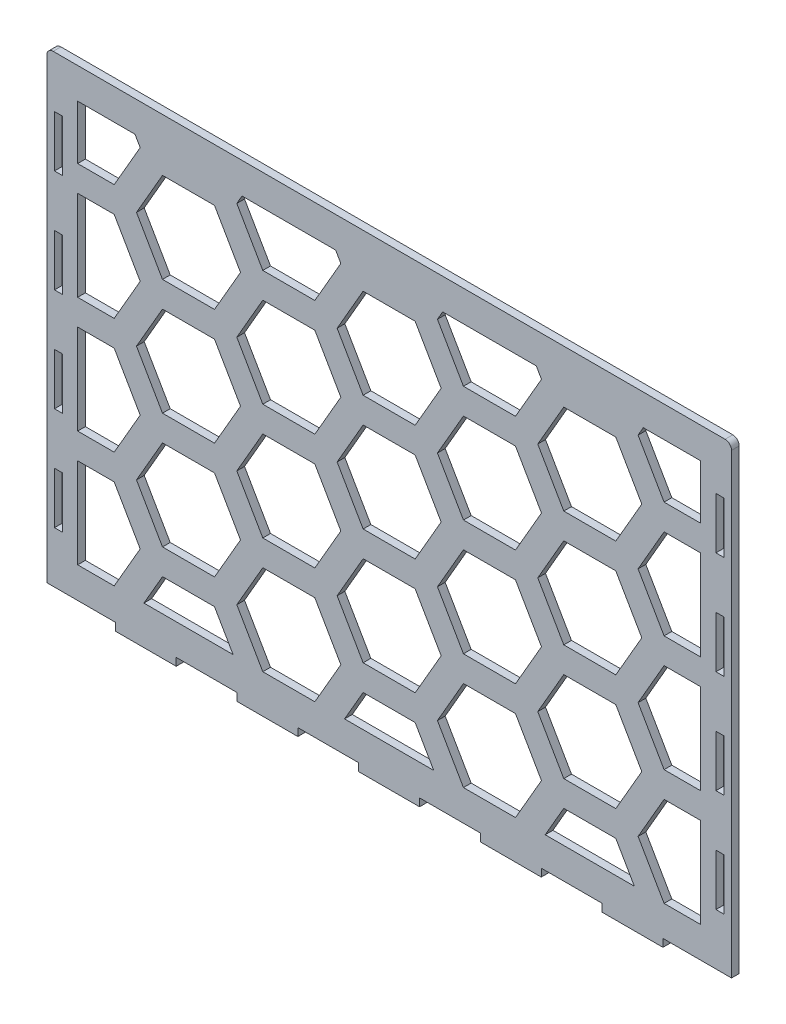
from build123d import *

# Parameters (mm, degrees)
SKETCH1_W           = 266
SKETCH1_H           = 180
SKETCH1_W_2         = 3.05
SKETCH1_H_2         = 20
SKETCH1_W_3         = 23.636363636
SKETCH1_H_3         = 3
SKETCH1_W_4         = 23.636363637
BOSS_EXTRUDE1_DEPTH = 3
FILLET1_R           = 2.5
CUT_EXTRUDE1_DEPTH  = 10


with BuildPart() as part:
    # Sketch1 → Boss-Extrude1 (new body)
    with BuildSketch(Plane.XY):
        Rectangle(SKETCH1_W, SKETCH1_H)
        with Locations((128.475, -20)):
            Rectangle(SKETCH1_W_2, SKETCH1_H_2, mode=Mode.SUBTRACT)
        with Locations((128.475, 20)):
            Rectangle(SKETCH1_W_2, SKETCH1_H_2, mode=Mode.SUBTRACT)
        with Locations((128.475, 60)):
            Rectangle(SKETCH1_W_2, SKETCH1_H_2, mode=Mode.SUBTRACT)
        with Locations((128.475, -60)):
            Rectangle(SKETCH1_W_2, SKETCH1_H_2, mode=Mode.SUBTRACT)
        with Locations((-128.475, 60)):
            Rectangle(SKETCH1_W_2, SKETCH1_H_2, mode=Mode.SUBTRACT)
        with Locations((-128.475, 20)):
            Rectangle(SKETCH1_W_2, SKETCH1_H_2, mode=Mode.SUBTRACT)
        with Locations((-128.475, -20)):
            Rectangle(SKETCH1_W_2, SKETCH1_H_2, mode=Mode.SUBTRACT)
        with Locations((-128.475, -60)):
            Rectangle(SKETCH1_W_2, SKETCH1_H_2, mode=Mode.SUBTRACT)
        with Locations((0, -91.5)):
            Rectangle(SKETCH1_W_3, SKETCH1_H_3)
        with Locations((47.272727273, -91.5)):
            Rectangle(SKETCH1_W_3, SKETCH1_H_3)
        with Locations((94.545454546, -91.5)):
            Rectangle(SKETCH1_W_4, SKETCH1_H_3)
        with Locations((-47.272727273, -91.5)):
            Rectangle(SKETCH1_W_3, SKETCH1_H_3)
        with Locations((-94.545454546, -91.5)):
            Rectangle(SKETCH1_W_4, SKETCH1_H_3)
    extrude(amount=BOSS_EXTRUDE1_DEPTH)

    # Fillet1
    fillet1_edges = [part.edges().sort_by_distance(p)[0] for p in [
        (-133, 90, 1.5),
        (133, 90, 1.5),
    ]]
    fillet(fillet1_edges, radius=FILLET1_R)

    # Sketch3 → Cut-Extrude1 (cut)
    with BuildSketch(Plane(origin=(0, 0, 0), x_dir=(-1, 0, 0), z_dir=(0, 0, -1))):
        Polygon((-121, -43), (-121, -78), (-106.8097998, -78), (-96.706170089, -60.5), (-106.8097998, -43), align=None)
        Polygon((-67.83865663, -55.5), (-57.735026919, -38), (-67.83865663, -20.5), (-88.045916051, -20.5), (-98.149545762, -38), (-88.045916051, -55.5), align=None)
        Polygon((-121, 2), (-121, -33), (-106.8097998, -33), (-96.706170089, -15.5), (-106.8097998, 2), align=None)
        Polygon((-121, 47), (-121, 12), (-106.8097998, 12), (-96.706170089, 29.5), (-106.8097998, 47), align=None)
        Polygon((-121, 78), (-121, 57), (-106.8097998, 57), (-96.706170089, 74.5), (-98.726896031, 78), align=None)
        Polygon((-67.83865663, 34.5), (-57.735026919, 52), (-67.83865663, 69.5), (-88.045916051, 69.5), (-98.149545762, 52), (-88.045916051, 34.5), align=None)
        Polygon((-20.784609691, 78), (-57.15767665, 78), (-59.178402592, 74.5), (-49.074772881, 57), (-28.867513459, 57), (-18.763883749, 74.5), align=None)
        Polygon((-28.867513459, 47), (-49.074772881, 47), (-59.178402592, 29.5), (-49.074772881, 12), (-28.867513459, 12), (-18.763883749, 29.5), align=None)
        Polygon((-67.83865663, -10.5), (-57.735026919, 7), (-67.83865663, 24.5), (-88.045916051, 24.5), (-98.149545762, 7), (-88.045916051, -10.5), align=None)
        Polygon((-28.867513459, 2), (-49.074772881, 2), (-59.178402592, -15.5), (-49.074772881, -33), (-28.867513459, -33), (-18.763883749, -15.5), align=None)
        Polygon((-28.867513459, -43), (-49.074772881, -43), (-59.178402592, -60.5), (-49.074772881, -78), (-28.867513459, -78), (-18.763883749, -60.5), align=None)
        Polygon((-88.045916051, -65.5), (-95.262794416, -78), (-60.621778265, -78), (-67.83865663, -65.5), align=None)
        Polygon((-10.103629711, -65.5), (-17.320508076, -78), (17.320508076, -78), (10.103629711, -65.5), align=None)
        Polygon((49.074772881, -43), (28.867513459, -43), (18.763883749, -60.5), (28.867513459, -78), (49.074772881, -78), (59.178402592, -60.5), align=None)
        Polygon((67.83865663, -65.5), (60.621778265, -78), (95.262794416, -78), (88.045916051, -65.5), align=None)
        Polygon((96.706170089, -60.5), (106.8097998, -78), (121, -78), (121, -43), (106.8097998, -43), align=None)
        Polygon((88.045916051, -55.5), (98.149545762, -38), (88.045916051, -20.5), (67.83865663, -20.5), (57.735026919, -38), (67.83865663, -55.5), align=None)
        Polygon((106.8097998, -33), (121, -33), (121, 2), (106.8097998, 2), (96.706170089, -15.5), align=None)
        Polygon((88.045916051, -10.5), (98.149545762, 7), (88.045916051, 24.5), (67.83865663, 24.5), (57.735026919, 7), (67.83865663, -10.5), align=None)
        Polygon((121, 12), (121, 47), (106.8097998, 47), (96.706170089, 29.5), (106.8097998, 12), align=None)
        Polygon((88.045916051, 34.5), (98.149545762, 52), (88.045916051, 69.5), (67.83865663, 69.5), (57.735026919, 52), (67.83865663, 34.5), align=None)
        Polygon((121, 78), (98.726896031, 78), (96.706170089, 74.5), (106.8097998, 57), (121, 57), align=None)
        Polygon((57.15767665, 78), (20.784609691, 78), (18.763883749, 74.5), (28.867513459, 57), (49.074772881, 57), (59.178402592, 74.5), align=None)
        Polygon((10.103629711, 34.5), (20.207259422, 52), (10.103629711, 69.5), (-10.103629711, 69.5), (-20.207259422, 52), (-10.103629711, 34.5), align=None)
        Polygon((49.074772881, 47), (28.867513459, 47), (18.763883749, 29.5), (28.867513459, 12), (49.074772881, 12), (59.178402592, 29.5), align=None)
        Polygon((10.103629711, -10.5), (20.207259422, 7), (10.103629711, 24.5), (-10.103629711, 24.5), (-20.207259422, 7), (-10.103629711, -10.5), align=None)
        Polygon((49.074772881, 2), (28.867513459, 2), (18.763883749, -15.5), (28.867513459, -33), (49.074772881, -33), (59.178402592, -15.5), align=None)
        Polygon((10.103629711, -55.5), (20.207259422, -38), (10.103629711, -20.5), (-10.103629711, -20.5), (-20.207259422, -38), (-10.103629711, -55.5), align=None)
    extrude(amount=-CUT_EXTRUDE1_DEPTH, mode=Mode.SUBTRACT)


solid = part.part
